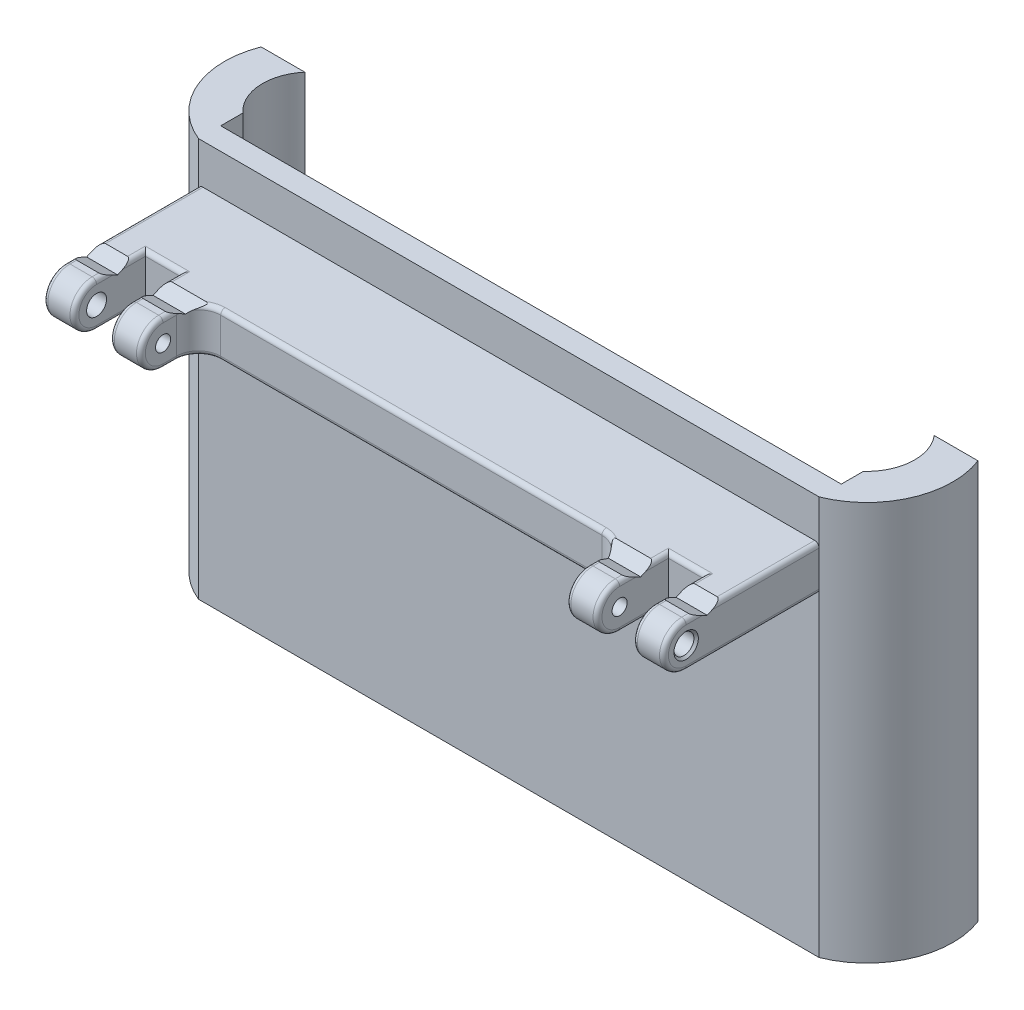
from build123d import *

# Parameters (mm, degrees)
BOSS_EXTRU_1_DEPTH      = 90
ESQUISSE2_W             = 140
ESQUISSE2_H             = 22
BOSS_EXTRU_2_DEPTH      = 10
ESQUISSE3_R             = 1.7
BOSS_EXTRU_3_DEPTH      = 140
ESQUISSE4_W             = 8
ESQUISSE4_H             = 15.226360619
ESQUISSE4_H_2           = 8
ESQUISSE4_H_3           = 3
ESQUISSE4_W_2           = 96
ENL_V_MAT_EXTRU_1_DEPTH = 10
ESQUISSE6_R             = 2.25
ENL_V_MAT_EXTRU_2_DEPTH = 10
CHANFREIN1_SIZE         = 0.5
CONG_4_R                = 5
CONG_1_R                = 1
ENL_V_MAT_EXTRU_4_DEPTH = 153.159710088


with BuildPart() as part:
    # Esquisse1 → Boss.-Extru.1 (new body)
    with BuildSketch(Plane(origin=(0, 0, 0), x_dir=(1, 0, 0), z_dir=(0, 1, 0))):
        with BuildLine():
            Line((-70, -6.538554455), (-70, -11.538554455))
            Line((-70, -11.538554455), (70, -11.538554455))
            Line((70, -11.538554455), (70, -6.538554455))
            ThreePointArc((70, -6.538554455), (73.525998754, 0.746669281), (71, 8.436043923))
            Line((71, 8.436043923), (80.865168939, 8.436043923))
            ThreePointArc((80.865168939, 8.436043923), (80.548331098, -6.276854674), (70, -16.538554455))
            Line((70, -16.538554455), (-70, -16.538554455))
            ThreePointArc((-70, -16.538554455), (-80.548331098, -6.276854674), (-80.865168939, 8.436043923))
            Line((-80.865168939, 8.436043923), (-71, 8.436043923))
            ThreePointArc((-71, 8.436043923), (-73.525998754, 0.746669281), (-70, -6.538554455))
        make_face()
    extrude(amount=BOSS_EXTRU_1_DEPTH)

    # Esquisse2 → Boss.-Extru.2 (add)
    with BuildSketch(Plane(origin=(0, 71, 0), x_dir=(-1, 0, 0), z_dir=(0, -1, 0))):
        with Locations((0, -27.538554455)):
            Rectangle(ESQUISSE2_W, ESQUISSE2_H)
    extrude(amount=-BOSS_EXTRU_2_DEPTH)

    # Esquisse3 → Boss.-Extru.3 (add)
    with BuildSketch(Plane.ZY.offset(70)):
        with BuildLine():
            Line((38.538554455, 71), (46.538554455, 71))
            ThreePointArc((46.538554455, 71), (51.538554455, 76), (46.538554455, 81))
            Line((46.538554455, 81), (38.538554455, 81))
            Line((38.538554455, 81), (38.538554455, 71))
        make_face()
        with Locations((46.538554455, 76)):
            Circle(ESQUISSE3_R, mode=Mode.SUBTRACT)
    extrude(amount=-BOSS_EXTRU_3_DEPTH)

    # Esquisse4 → Enl_v. mat.-Extru.1 (cut)
    with BuildSketch(Plane(origin=(0, 81, 0), x_dir=(1, 0, 0), z_dir=(0, 1, 0))):
        with Locations((-59, -54.151734765)):
            Rectangle(ESQUISSE4_W, ESQUISSE4_H)
        with Locations((-59, -42.538554455)):
            Rectangle(ESQUISSE4_W, ESQUISSE4_H_2)
        with Locations((-59, -37.038554455)):
            Rectangle(ESQUISSE4_W, ESQUISSE4_H_3)
        with Locations((0, -42.538554455)):
            Rectangle(ESQUISSE4_W_2, ESQUISSE4_H_2)
        with Locations((0, -54.151734765)):
            Rectangle(ESQUISSE4_W_2, ESQUISSE4_H)
        with Locations((59, -54.151734765)):
            Rectangle(ESQUISSE4_W, ESQUISSE4_H)
        with Locations((59, -42.538554455)):
            Rectangle(ESQUISSE4_W, ESQUISSE4_H_2)
        with Locations((59, -37.038554455)):
            Rectangle(ESQUISSE4_W, ESQUISSE4_H_3)
    extrude(amount=-ENL_V_MAT_EXTRU_1_DEPTH, mode=Mode.SUBTRACT)

    # Esquisse6 → Enl_v. mat.-Extru.2 (cut)
    with BuildSketch(Plane.ZY.offset(70)):
        with Locations((46.538554455, 76)):
            Circle(ESQUISSE6_R)
    enl_v_mat_extru_2 = extrude(amount=-ENL_V_MAT_EXTRU_2_DEPTH, mode=Mode.SUBTRACT)

    # Sym_trie1: Enl_v. mat.-Extru.2 across plane
    add(enl_v_mat_extru_2.mirror(Plane(origin=(0, 0, 0), x_dir=(0, 0, 1), z_dir=(1, 0, 0))), mode=Mode.SUBTRACT)

    # Chanfrein1
    chanfrein1_edges = [part.edges().sort_by_distance(p)[0] for p in [
        (-70, 76, 44.288554455),
        (70, 76, 44.288554455),
    ]]
    chamfer(chanfrein1_edges, length=CHANFREIN1_SIZE)

    # Cong_4
    cong_4_edges = [part.edges().sort_by_distance(p)[0] for p in [
        (48, 76, 38.538554455),
        (-48, 76, 38.538554455),
    ]]
    fillet(cong_4_edges, radius=CONG_4_R)

    # Cong_1
    cong_1_edges = [part.edges().sort_by_distance(p)[0] for p in [
        (59, 71, 35.538554455),
        (63, 71, 41.038554455),
        (55, 81, 41.038554455),
        (63, 81, 41.038554455),
        (63, 76, 51.538554455),
        (55, 76, 51.538554455),
        (55, 71, 41.038554455),
        (59, 81, 35.538554455),
        (0, 81, 38.538554455),
        (0, 71, 38.538554455),
        (48, 81, 45.038554455),
        (48, 71, 45.038554455),
        (-48, 71, 45.038554455),
        (-48, 81, 45.038554455),
        (46.535533906, 81, 40.003020549),
        (46.535533906, 71, 40.003020549),
        (-46.535533906, 81, 40.003020549),
        (-46.535533906, 71, 40.003020549),
        (70, 81, 31.538554455),
        (-70, 81, 31.538554455),
        (70, 71, 31.538554455),
        (-70, 71, 31.538554455),
        (70, 76, 51.538554455),
        (-70, 76, 51.538554455),
        (-59, 71, 35.538554455),
        (-55, 71, 41.038554455),
        (-63, 81, 41.038554455),
        (-55, 81, 41.038554455),
        (-55, 76, 51.538554455),
        (-63, 76, 51.538554455),
        (-63, 71, 41.038554455),
        (-59, 81, 35.538554455),
        (48, 76, 51.538554455),
        (-48, 76, 51.538554455),
    ]]
    fillet(cong_1_edges, radius=CONG_1_R)

    # Esquisse8 → Enl_v. mat.-Extru.4 (cut, through all)
    with BuildSketch(Plane.ZY.offset(70)):
        Polygon((45.038554455, 81), (41.788554455, 79.5), (38.538554455, 81), align=None)
    extrude(amount=-ENL_V_MAT_EXTRU_4_DEPTH, mode=Mode.SUBTRACT)


solid = part.part
